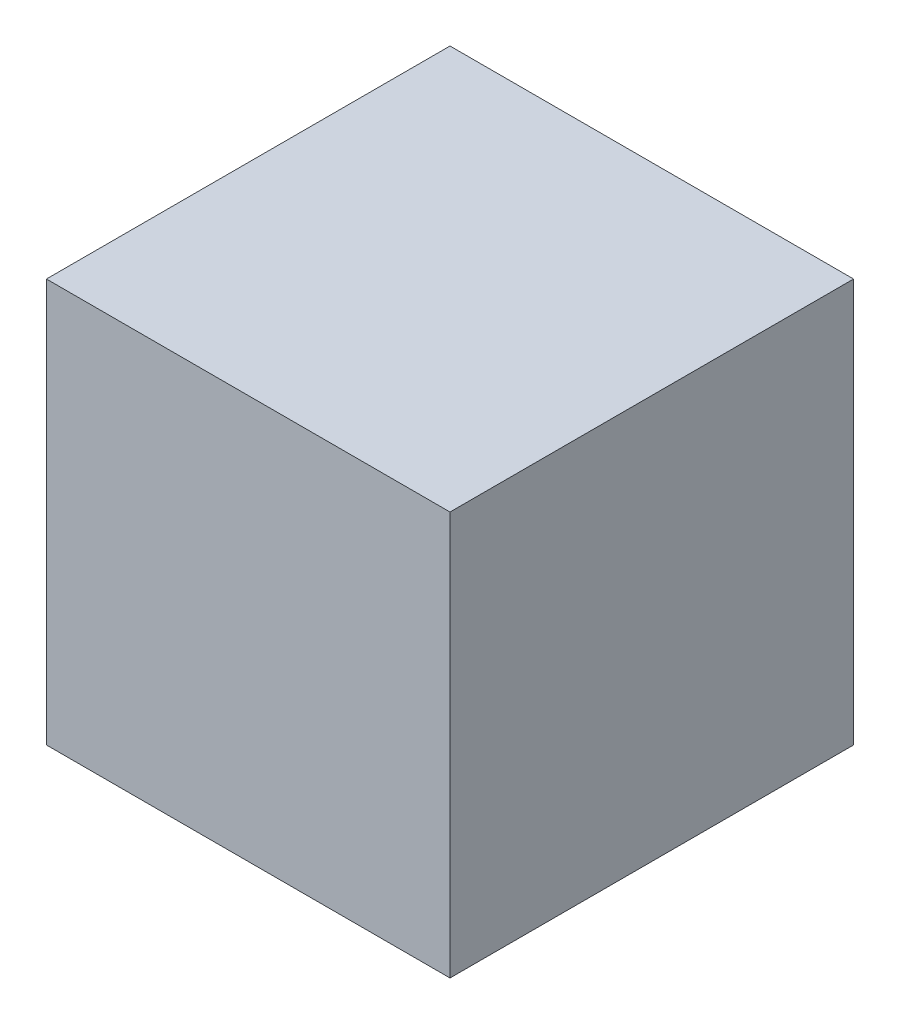
from build123d import *

# Parameters (mm, degrees)
SKETCH1_W           = 508.001016002
SKETCH1_H           = 508.001016002
BOSS_EXTRUDE1_DEPTH = 508.001016002


with BuildPart() as part:
    # Sketch1 → Boss-Extrude1 (new body)
    with BuildSketch(Plane.XY):
        Rectangle(SKETCH1_W, SKETCH1_H)
    extrude(amount=BOSS_EXTRUDE1_DEPTH)


solid = part.part
